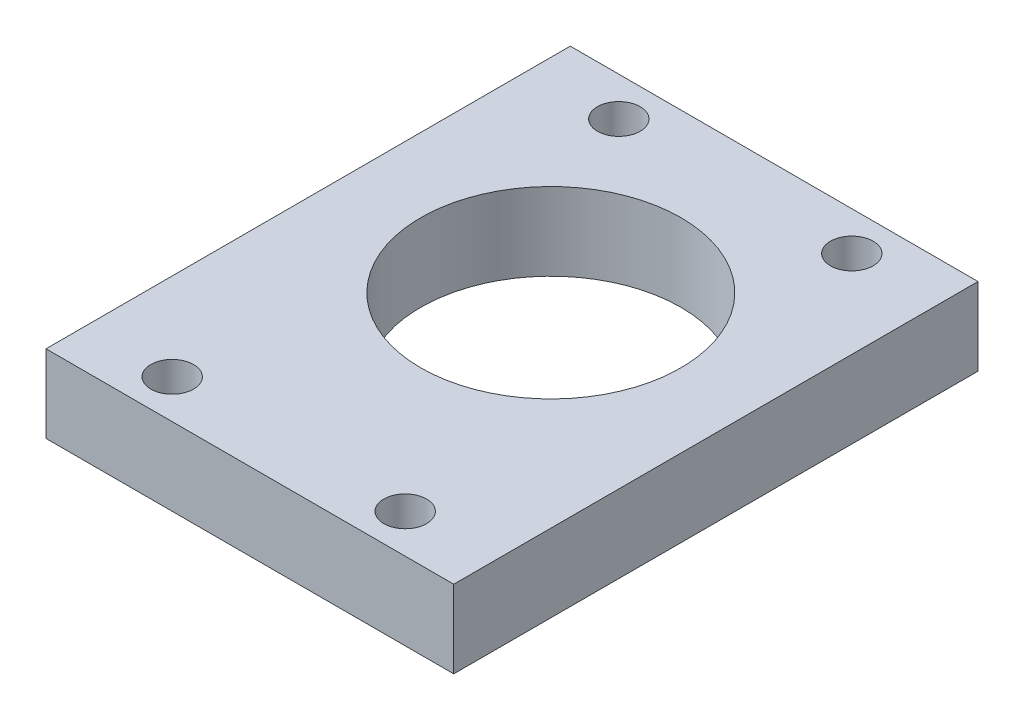
from build123d import *

# Parameters (mm, degrees)
ESQUISSE1_W             = 42
ESQUISSE1_H             = 62
ESQUISSE1_R             = 13.4
BOSS_EXTRU_1_DEPTH      = 8
ENL_V_MAT_EXTRU_2_REACH = 10
ESQUISSE3_W             = 42
ESQUISSE3_H             = 8
ESQUISSE2_R             = 2.2
ENL_V_MAT_EXTRU_1_DEPTH = 9


with BuildPart() as part:
    # Esquisse1 → Boss.-Extru.1 (new body)
    with BuildSketch(Plane(origin=(0, 0, 0), x_dir=(1, 0, 0), z_dir=(0, 1, 0))):
        with Locations((21, 31)):
            Rectangle(ESQUISSE1_W, ESQUISSE1_H)
        with Locations((21, 31)):
            Circle(ESQUISSE1_R, mode=Mode.SUBTRACT)
    extrude(amount=BOSS_EXTRU_1_DEPTH)

    # Esquisse3 → Enlèv. mat.-Extru.2 (cut, up to next)
    with BuildSketch(Plane(origin=(0, 8, 0), x_dir=(1, 0, 0), z_dir=(0, 1, 0)), mode=Mode.PRIVATE) as enl_v_mat_extru_2_sk1:
        with Locations((21, 58)):
            Rectangle(ESQUISSE3_W, ESQUISSE3_H)
    enl_v_mat_extru_2_tool1 = extrude(enl_v_mat_extru_2_sk1.sketch, amount=-ENL_V_MAT_EXTRU_2_REACH, mode=Mode.PRIVATE) & part.part
    add(enl_v_mat_extru_2_tool1.solids().sort_by_distance((21, 8, -58))[0], mode=Mode.SUBTRACT)

    # Esquisse2 → Enlèv. mat.-Extru.1 (cut, through all)
    with BuildSketch(Plane(origin=(0, 8, 0), x_dir=(1, 0, 0), z_dir=(0, 1, 0))):
        with Locations((9, 50)):
            Circle(ESQUISSE2_R)
        with Locations((33, 50)):
            Circle(ESQUISSE2_R)
        with Locations((33, 4)):
            Circle(ESQUISSE2_R)
        with Locations((9, 4)):
            Circle(ESQUISSE2_R)
    extrude(amount=-ENL_V_MAT_EXTRU_1_DEPTH, mode=Mode.SUBTRACT)


solid = part.part
